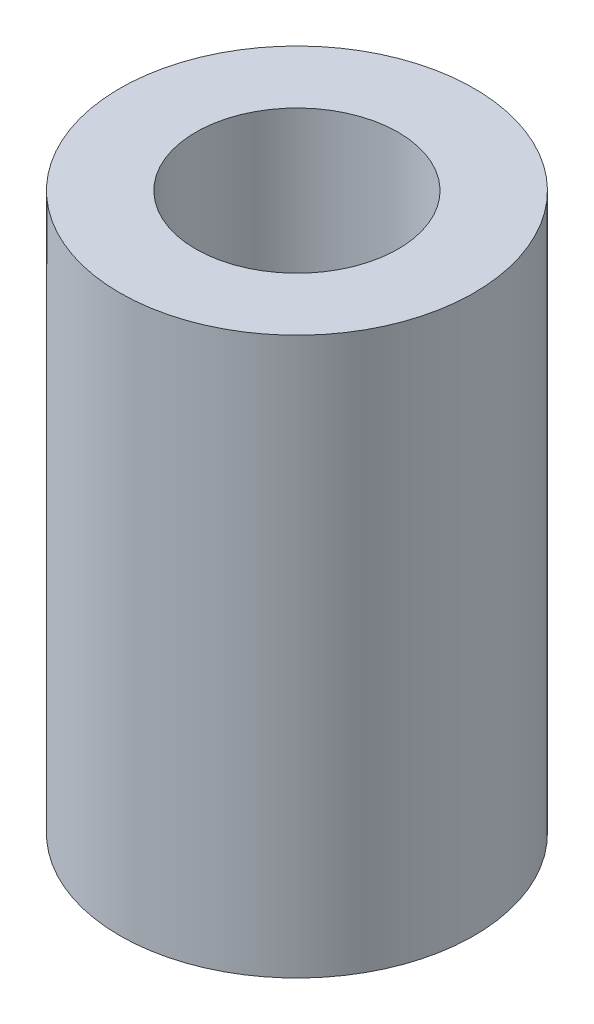
from build123d import *

# Parameters (mm, degrees)
SKETCH1_R           = 7
SKETCH1_R_2         = 2.5
BOSS_EXTRUDE1_DEPTH = 22
SKETCH2_R           = 4
CUT_EXTRUDE1_DEPTH  = 11


with BuildPart() as part:
    # Sketch1 → Boss-Extrude1 (new body)
    with BuildSketch(Plane(origin=(0, 0, 0), x_dir=(1, 0, 0), z_dir=(0, 1, 0))):
        Circle(SKETCH1_R)
        Circle(SKETCH1_R_2, mode=Mode.SUBTRACT)
    extrude(amount=BOSS_EXTRUDE1_DEPTH)

    # Sketch2 → Cut-Extrude1 (cut)
    with BuildSketch(Plane(origin=(0, 22, 0), x_dir=(1, 0, 0), z_dir=(0, 1, 0))):
        Circle(SKETCH2_R)
    extrude(amount=-CUT_EXTRUDE1_DEPTH, mode=Mode.SUBTRACT)


solid = part.part
